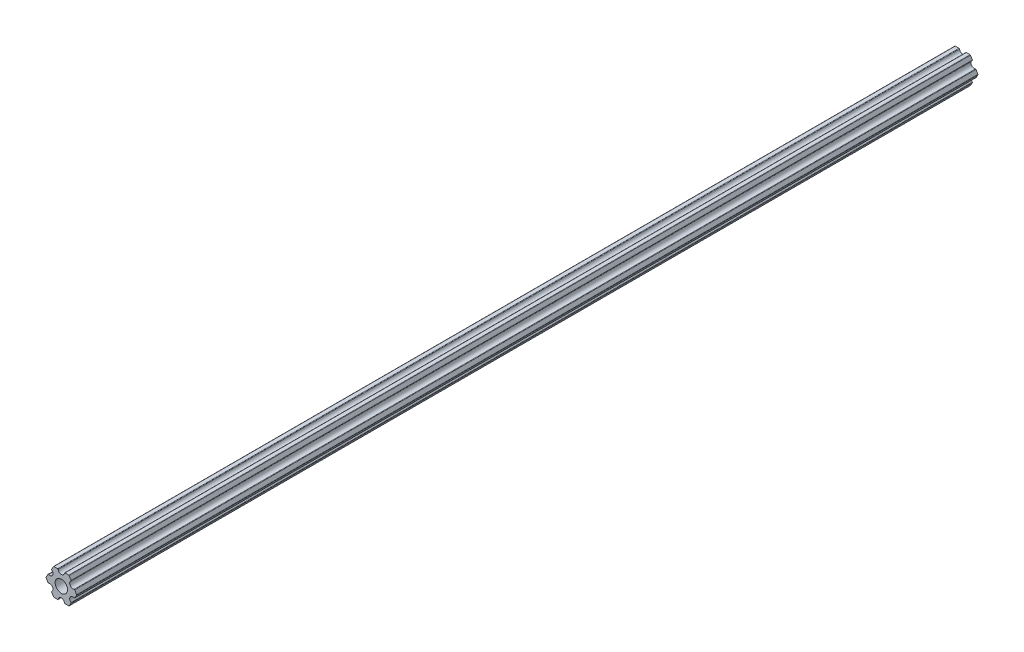
from build123d import *

# Parameters (mm, degrees)
SKETCH1_R         = 2.9337
EXTRUDE1_DEPTH    = 214.3125
SKETCH5_R         = 1.524
EXTRUDE2_DEPTH    = 429.625
CIRPATTERN2_COUNT = 6
FILLET1_R         = 0.254


with BuildPart() as part:
    # Sketch1 → Extrude1 (new body, symmetric)
    with BuildSketch(Plane.XY):
        Polygon((7.332348419, 0), (3.666174209, 6.35), (-3.666174209, 6.35), (-7.332348419, 0), (-3.666174209, -6.35), (3.666174209, -6.35), align=None)
        Circle(SKETCH1_R, mode=Mode.SUBTRACT)
    extrude(amount=EXTRUDE1_DEPTH, both=True)

    # Sketch5 → Extrude2 (cut, through all)
    with BuildSketch(Plane.XY.offset(214.3125)):
        with Locations((0, 6.35)):
            Circle(SKETCH5_R)
    extrude2 = extrude(amount=-EXTRUDE2_DEPTH, mode=Mode.SUBTRACT)

    # CirPattern2: Extrude2 ×6 about axis
    cirpattern2_axis = Axis((0, 0, 0), (0, 0, 1))
    for i in range(1, CIRPATTERN2_COUNT):
        add(extrude2.rotate(cirpattern2_axis, i * 360 / CIRPATTERN2_COUNT), mode=Mode.SUBTRACT)

    # Fillet1
    fillet1_edges = [part.edges().sort_by_distance(p)[0] for p in [
        (3.666174209, -6.35, 0),
        (-3.666174209, -6.35, 0),
        (-7.332348419, 0, 0),
        (-3.666174209, 6.35, 0),
        (3.666174209, 6.35, 0),
        (7.332348419, 0, 0),
        (-1.524, 6.35, 0),
        (1.524, 6.35, 0),
        (-6.261261314, 1.855177285, 0),
        (-4.737261314, 4.494822715, 0),
        (-4.737261314, -4.494822715, 0),
        (-6.261261314, -1.855177285, 0),
        (1.524, -6.35, 0),
        (-1.524, -6.35, 0),
        (6.261261314, -1.855177285, 0),
        (4.737261314, -4.494822715, 0),
        (4.737261314, 4.494822715, 0),
        (6.261261314, 1.855177285, 0),
    ]]
    fillet(fillet1_edges, radius=FILLET1_R)


solid = part.part
